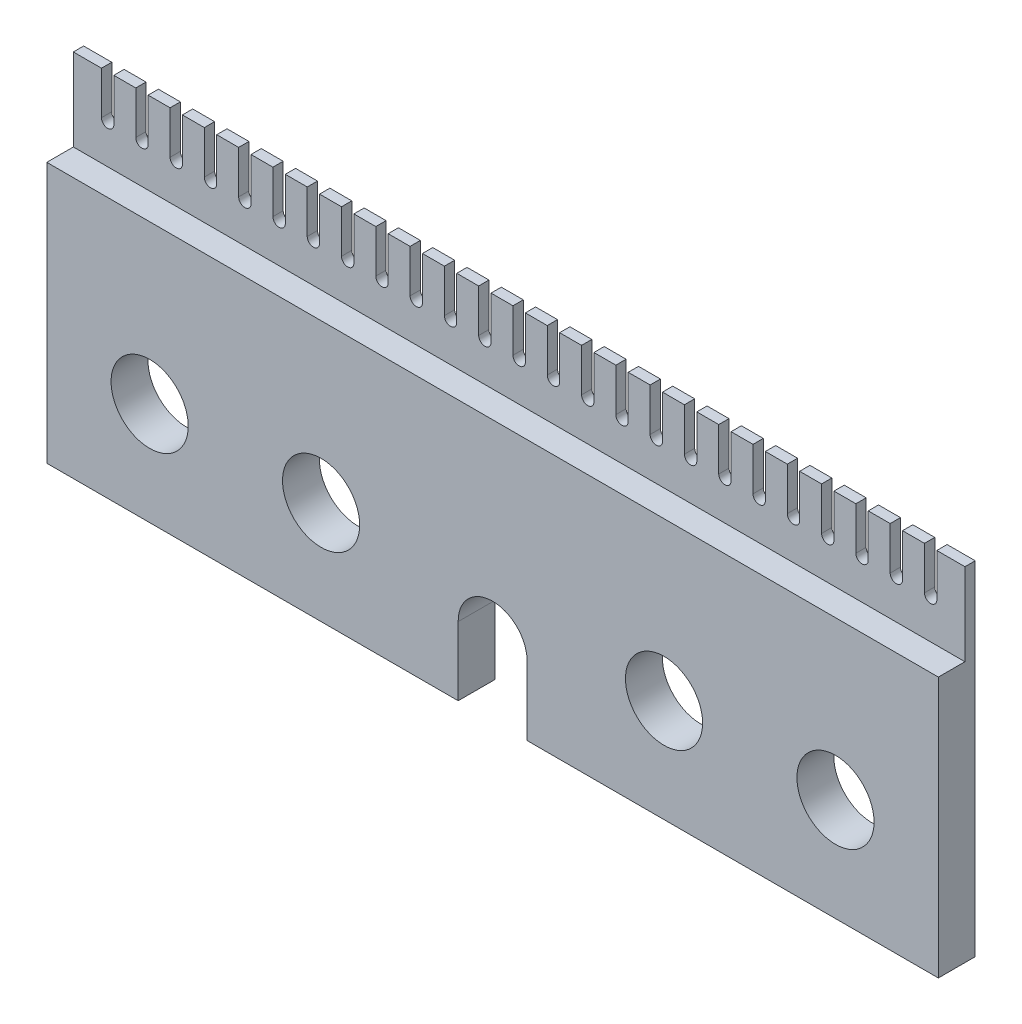
from build123d import *

# Parameters (mm, degrees)
SKETCH1_R           = 2.25
BOSS_EXTRUDE1_DEPTH = 2.15
SKETCH2_W           = 1.55
SKETCH2_H           = 4.8
CUT_EXTRUDE1_DEPTH  = 53


with BuildPart() as part:
    # Sketch1 → Boss-Extrude1 (new body)
    with BuildSketch(Plane.XY):
        with BuildLine():
            Line((2.398752887, -11.327345722), (26.384379929, -11.327345722))
            Line((26.384379929, -11.327345722), (26.384379929, 8.672654278))
            Line((26.384379929, 8.672654278), (26.024379959, 8.672654278))
            Line((26.024379959, 8.672654278), (24.744379959, 8.672654278))
            Line((24.744379959, 8.672654278), (24.744379959, 6.172654278))
            ThreePointArc((24.744379959, 6.172654278), (24.384379958, 5.812654278), (24.024379958, 6.172654278))
            Line((24.024379958, 6.172654278), (24.024379958, 8.672654278))
            Line((24.024379958, 8.672654278), (22.744379958, 8.672654278))
            Line((22.744379958, 8.672654278), (22.744379958, 6.172654278))
            ThreePointArc((22.744379958, 6.172654278), (22.384379957, 5.812654278), (22.024379957, 6.172654278))
            Line((22.024379957, 6.172654278), (22.024379957, 8.672654278))
            Line((22.024379957, 8.672654278), (20.744379957, 8.672654278))
            Line((20.744379957, 8.672654278), (20.744379957, 6.172654278))
            ThreePointArc((20.744379957, 6.172654278), (20.384379956, 5.812654278), (20.024379956, 6.172654278))
            Line((20.024379956, 6.172654278), (20.024379956, 8.672654278))
            Line((20.024379956, 8.672654278), (18.744379956, 8.672654278))
            Line((18.744379956, 8.672654278), (18.744379956, 6.172654278))
            ThreePointArc((18.744379956, 6.172654278), (18.384379955, 5.812654278), (18.024379955, 6.172654278))
            Line((18.024379955, 6.172654278), (18.024379955, 8.672654278))
            Line((18.024379955, 8.672654278), (16.744379955, 8.672654278))
            Line((16.744379955, 8.672654278), (16.744379955, 6.172654278))
            ThreePointArc((16.744379955, 6.172654278), (16.384379953, 5.812654278), (16.024379953, 6.172654278))
            Line((16.024379953, 6.172654278), (16.024379953, 8.672654278))
            Line((16.024379953, 8.672654278), (14.744379953, 8.672654278))
            Line((14.744379953, 8.672654278), (14.744379953, 6.172654278))
            ThreePointArc((14.744379953, 6.172654278), (14.384379952, 5.812654278), (14.024379952, 6.172654278))
            Line((14.024379952, 6.172654278), (14.024379952, 8.672654278))
            Line((14.024379952, 8.672654278), (12.744379952, 8.672654278))
            Line((12.744379952, 8.672654278), (12.744379952, 6.172654278))
            ThreePointArc((12.744379952, 6.172654278), (12.384379951, 5.812654278), (12.024379951, 6.172654278))
            Line((12.024379951, 6.172654278), (12.024379951, 8.672654278))
            Line((12.024379951, 8.672654278), (10.744379951, 8.672654278))
            Line((10.744379951, 8.672654278), (10.744379951, 6.172654278))
            ThreePointArc((10.744379951, 6.172654278), (10.38437995, 5.812654278), (10.02437995, 6.172654278))
            Line((10.02437995, 6.172654278), (10.02437995, 8.672654278))
            Line((10.02437995, 8.672654278), (8.74437995, 8.672654278))
            Line((8.74437995, 8.672654278), (8.74437995, 6.172654278))
            ThreePointArc((8.74437995, 6.172654278), (8.384379949, 5.812654278), (8.024379949, 6.172654278))
            Line((8.024379949, 6.172654278), (8.024379949, 8.672654278))
            Line((8.024379949, 8.672654278), (6.744379949, 8.672654278))
            Line((6.744379949, 8.672654278), (6.744379949, 6.172654278))
            ThreePointArc((6.744379949, 6.172654278), (6.384379947, 5.812654278), (6.024379947, 6.172654278))
            Line((6.024379947, 6.172654278), (6.024379947, 8.672654278))
            Line((6.024379947, 8.672654278), (4.744379947, 8.672654278))
            Line((4.744379947, 8.672654278), (4.744379947, 6.172654278))
            ThreePointArc((4.744379947, 6.172654278), (4.384379946, 5.812654278), (4.024379946, 6.172654278))
            Line((4.024379946, 6.172654278), (4.024379946, 8.672654278))
            Line((4.024379946, 8.672654278), (2.744379946, 8.672654278))
            Line((2.744379946, 8.672654278), (2.744379946, 6.172654278))
            ThreePointArc((2.744379946, 6.172654278), (2.384379945, 5.812654278), (2.024379945, 6.172654278))
            Line((2.024379945, 6.172654278), (2.024379945, 8.672654278))
            Line((2.024379945, 8.672654278), (0.744379945, 8.672654278))
            Line((0.744379945, 8.672654278), (0.744379945, 6.172654278))
            ThreePointArc((0.744379945, 6.172654278), (0.384379944, 5.812654278), (0.024379944, 6.172654278))
            Line((0.024379944, 6.172654278), (0.024379944, 8.672654278))
            Line((0.024379944, 8.672654278), (-1.255620056, 8.672654278))
            Line((-1.255620056, 8.672654278), (-1.255620056, 6.172654278))
            ThreePointArc((-1.255620056, 6.172654278), (-1.615620057, 5.812654278), (-1.975620057, 6.172654278))
            Line((-1.975620057, 6.172654278), (-1.975620057, 8.672654278))
            Line((-1.975620057, 8.672654278), (-3.255620057, 8.672654278))
            Line((-3.255620057, 8.672654278), (-3.255620057, 6.172654278))
            ThreePointArc((-3.255620057, 6.172654278), (-3.615620059, 5.812654278), (-3.975620059, 6.172654278))
            Line((-3.975620059, 6.172654278), (-3.975620059, 8.672654278))
            Line((-3.975620059, 8.672654278), (-5.255620059, 8.672654278))
            Line((-5.255620059, 8.672654278), (-5.255620059, 6.172654278))
            ThreePointArc((-5.255620059, 6.172654278), (-5.61562006, 5.812654278), (-5.97562006, 6.172654278))
            Line((-5.97562006, 6.172654278), (-5.97562006, 8.672654278))
            Line((-5.97562006, 8.672654278), (-7.25562006, 8.672654278))
            Line((-7.25562006, 8.672654278), (-7.25562006, 6.172654278))
            ThreePointArc((-7.25562006, 6.172654278), (-7.615620061, 5.812654278), (-7.975620061, 6.172654278))
            Line((-7.975620061, 6.172654278), (-7.975620061, 8.672654278))
            Line((-7.975620061, 8.672654278), (-9.255620061, 8.672654278))
            Line((-9.255620061, 8.672654278), (-9.255620061, 6.172654278))
            ThreePointArc((-9.255620061, 6.172654278), (-9.615620062, 5.812654278), (-9.975620062, 6.172654278))
            Line((-9.975620062, 6.172654278), (-9.975620062, 8.672654278))
            Line((-9.975620062, 8.672654278), (-11.255620062, 8.672654278))
            Line((-11.255620062, 8.672654278), (-11.255620062, 6.172654278))
            ThreePointArc((-11.255620062, 6.172654278), (-11.615620063, 5.812654278), (-11.975620063, 6.172654278))
            Line((-11.975620063, 6.172654278), (-11.975620063, 8.672654278))
            Line((-11.975620063, 8.672654278), (-13.255620063, 8.672654278))
            Line((-13.255620063, 8.672654278), (-13.255620063, 6.172654278))
            ThreePointArc((-13.255620063, 6.172654278), (-13.615620065, 5.812654278), (-13.975620065, 6.172654278))
            Line((-13.975620065, 6.172654278), (-13.975620065, 8.672654278))
            Line((-13.975620065, 8.672654278), (-15.255620065, 8.672654278))
            Line((-15.255620065, 8.672654278), (-15.255620065, 6.172654278))
            ThreePointArc((-15.255620065, 6.172654278), (-15.615620066, 5.812654278), (-15.975620066, 6.172654278))
            Line((-15.975620066, 6.172654278), (-15.975620066, 8.672654278))
            Line((-15.975620066, 8.672654278), (-17.255620066, 8.672654278))
            Line((-17.255620066, 8.672654278), (-17.255620066, 6.172654278))
            ThreePointArc((-17.255620066, 6.172654278), (-17.615620067, 5.812654278), (-17.975620067, 6.172654278))
            Line((-17.975620067, 6.172654278), (-17.975620067, 8.672654278))
            Line((-17.975620067, 8.672654278), (-19.255620067, 8.672654278))
            Line((-19.255620067, 8.672654278), (-19.255620067, 6.172654278))
            ThreePointArc((-19.255620067, 6.172654278), (-19.615620068, 5.812654278), (-19.975620068, 6.172654278))
            Line((-19.975620068, 6.172654278), (-19.975620068, 8.672654278))
            Line((-19.975620068, 8.672654278), (-21.255620068, 8.672654278))
            Line((-21.255620068, 8.672654278), (-21.255620068, 6.172654278))
            ThreePointArc((-21.255620068, 6.172654278), (-21.615620069, 5.812654278), (-21.975620069, 6.172654278))
            Line((-21.975620069, 6.172654278), (-21.975620069, 8.672654278))
            Line((-21.975620069, 8.672654278), (-23.255620069, 8.672654278))
            Line((-23.255620069, 8.672654278), (-23.255620069, 6.172654278))
            ThreePointArc((-23.255620069, 6.172654278), (-23.615620071, 5.812654278), (-23.975620071, 6.172654278))
            Line((-23.975620071, 6.172654278), (-23.975620071, 8.672654278))
            Line((-23.975620071, 8.672654278), (-25.615620071, 8.672654278))
            Line((-25.615620071, 8.672654278), (-25.615620071, -11.327345722))
            Line((-25.615620071, -11.327345722), (-1.621247113, -11.327345722))
            Line((-1.621247113, -11.327345722), (-1.621247113, -7.327345722))
            ThreePointArc((-1.621247113, -7.327345722), (0.373417474, -5.293808364), (2.398752887, -7.296800492))
            Line((2.398752887, -7.296800492), (2.398752887, -11.327345722))
        make_face()
        with Locations((-19.615620071, -5.327345722)):
            Circle(SKETCH1_R, mode=Mode.SUBTRACT)
        with Locations((-9.615620071, -5.327345722)):
            Circle(SKETCH1_R, mode=Mode.SUBTRACT)
        with Locations((10.384379929, -5.327345722)):
            Circle(SKETCH1_R, mode=Mode.SUBTRACT)
        with Locations((20.384379929, -5.327345722)):
            Circle(SKETCH1_R, mode=Mode.SUBTRACT)
    extrude(amount=BOSS_EXTRUDE1_DEPTH)

    # Sketch2 → Cut-Extrude1 (cut, through all)
    with BuildSketch(Plane.ZY.offset(25.615620071)):
        with Locations((1.375, 6.272654278)):
            Rectangle(SKETCH2_W, SKETCH2_H)
    extrude(amount=-CUT_EXTRUDE1_DEPTH, mode=Mode.SUBTRACT)


solid = part.part
